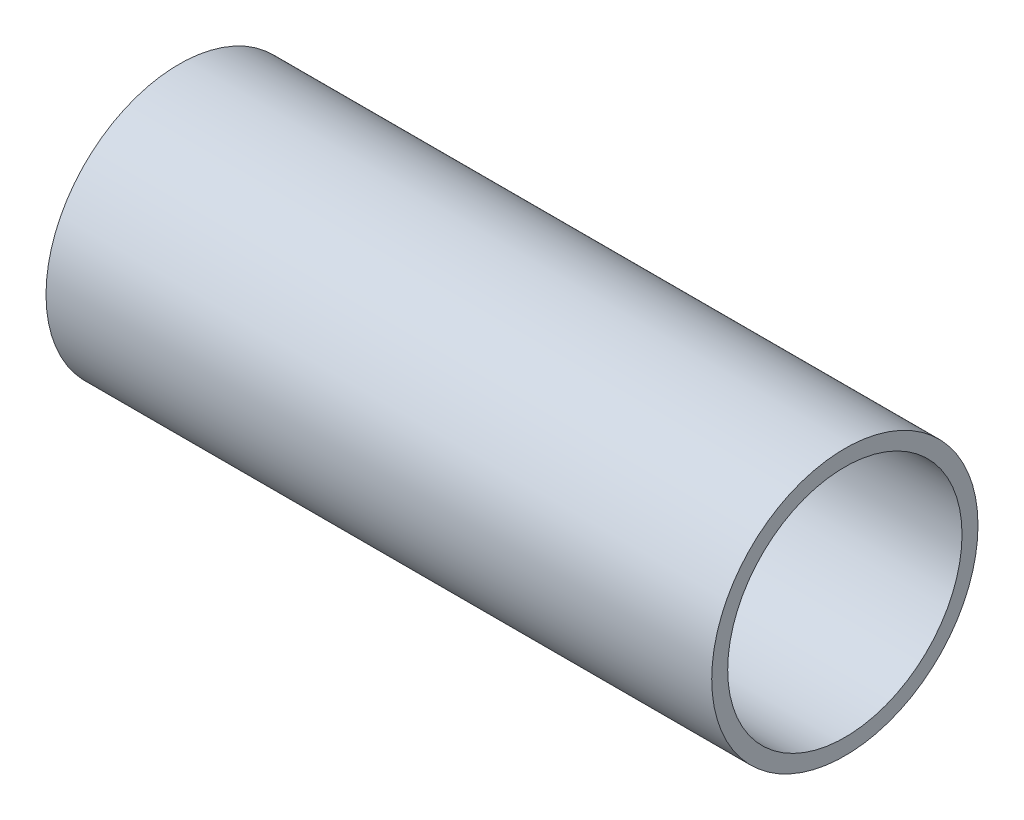
from build123d import *

# Parameters (mm, degrees)
SKETCH_1_R      = 25
SKETCH_1_R_2    = 22
EXTRUDE_1_DEPTH = 125


with BuildPart() as part:
    # 草圖1 → 填料-伸長1 (new body)
    with BuildSketch(Plane(origin=(0, 0, 0), x_dir=(0, 0, -1), z_dir=(1, 0, 0))):
        with Locations((-1.396629742, 0)):
            Circle(SKETCH_1_R)
        with Locations((-1.396629742, 0)):
            Circle(SKETCH_1_R_2, mode=Mode.SUBTRACT)
    extrude(amount=EXTRUDE_1_DEPTH)


solid = part.part
